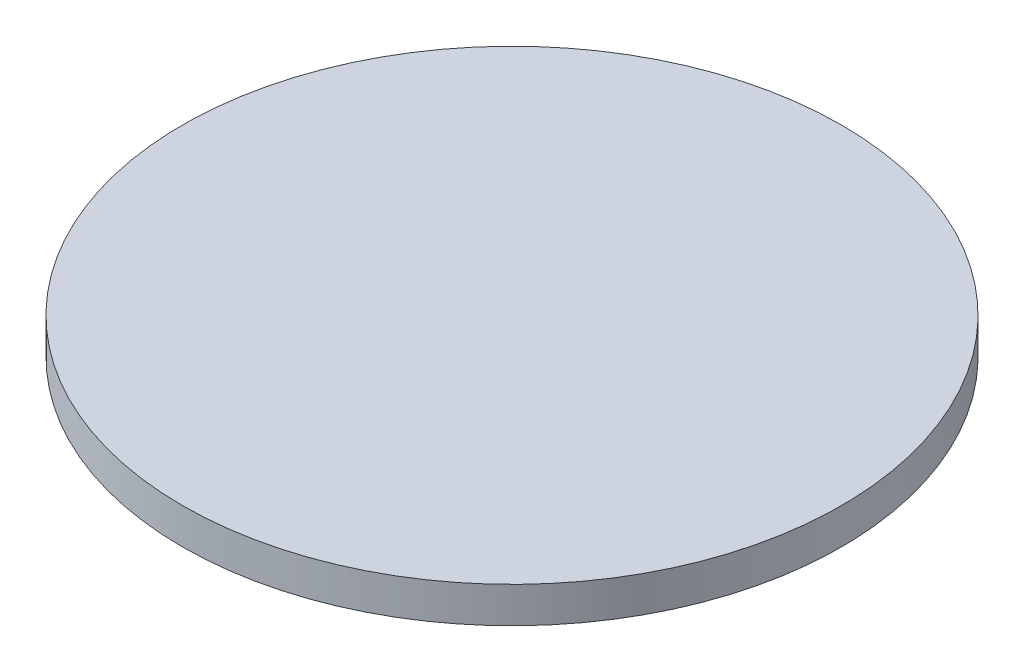
from build123d import *

# Parameters (mm, degrees)
SKETCH_1_R      = 12.5
EXTRUDE_1_DEPTH = 1.36


with BuildPart() as part:
    # 草图1 → 凸台-拉伸1 (new body)
    with BuildSketch(Plane(origin=(0, 0, 0), x_dir=(1, 0, 0), z_dir=(0, 1, 0))):
        with Locations(Location((0, 0, 0), (0, 0, 270))):  # turned: the seam where the file's is
            Circle(SKETCH_1_R)
    extrude(amount=EXTRUDE_1_DEPTH)


solid = part.part
